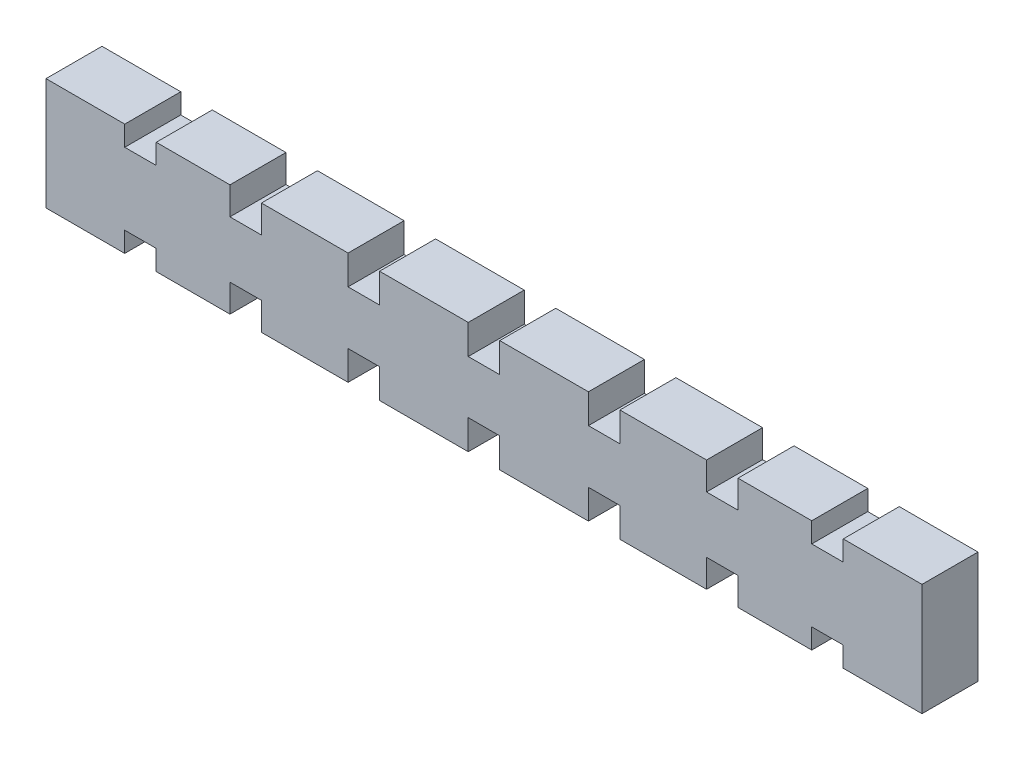
from build123d import *

# Parameters (mm, degrees)
BOSS_EXTRUDE1_DEPTH = 3.556


with BuildPart() as part:
    # Sketch1 → Boss-Extrude1 (new body)
    with BuildSketch(Plane.XY):
        Polygon((27.81, -3.556), (27.81, 3.556), (22.81, 3.556), (22.81, 2.28), (20.81, 2.28), (20.81, 3.556), (16.13, 3.556), (16.13, 1.795), (14.13, 1.795), (14.13, 3.556), (8.63, 3.556), (8.63, 1.695), (6.63, 1.695), (6.63, 3.556), (1, 3.556), (1, 1.68), (-1, 1.68), (-1, 3.556), (-6.63, 3.556), (-6.63, 1.695), (-8.63, 1.695), (-8.63, 3.556), (-14.13, 3.556), (-14.13, 1.795), (-16.13, 1.795), (-16.13, 3.556), (-20.81, 3.556), (-20.81, 2.28), (-22.81, 2.28), (-22.81, 3.556), (-27.81, 3.556), (-27.81, -3.556), (-22.81, -3.556), (-22.81, -2.28), (-20.81, -2.28), (-20.81, -3.556), (-16.13, -3.556), (-16.13, -1.795), (-14.13, -1.795), (-14.13, -3.556), (-8.63, -3.556), (-8.63, -1.695), (-6.63, -1.695), (-6.63, -3.556), (-1, -3.556), (-1, -1.68), (1, -1.68), (1, -3.556), (6.63, -3.556), (6.63, -1.695), (8.63, -1.695), (8.63, -3.556), (14.13, -3.556), (14.13, -1.795), (16.13, -1.795), (16.13, -3.556), (20.81, -3.556), (20.81, -2.28), (22.81, -2.28), (22.81, -3.556), align=None)
    extrude(amount=BOSS_EXTRUDE1_DEPTH)


solid = part.part
